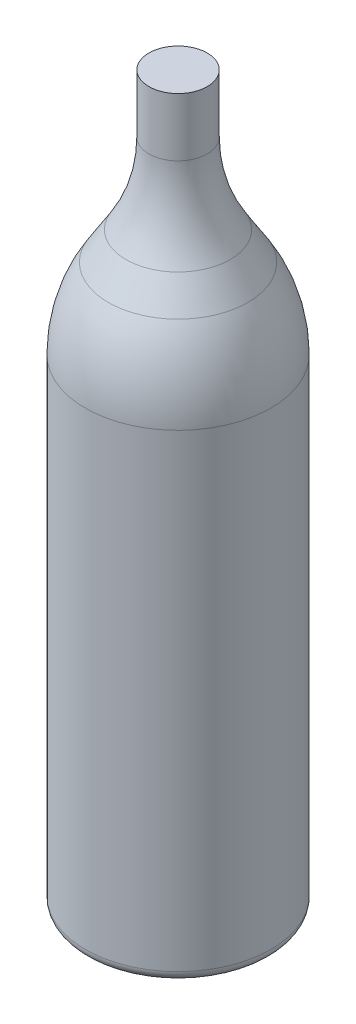
from build123d import *


with BuildPart() as part:
    # Sketch2 → Revolve1 (revolve)
    with BuildSketch(Plane.XY):
        with BuildLine():
            Line((0, 274), (-11, 274))
            Line((-11, 274), (-11, 252))
            ThreePointArc((-11, 252), (-13.208083332, 236.288670718), (-19.661258519, 221.794601939))
            Line((-19.661258519, 221.794601939), (-26.338741481, 211.108395388))
            ThreePointArc((-26.338741481, 211.108395388), (-32.791916668, 196.614326608), (-35, 180.902997327))
            Line((-35, 180.902997327), (-35, 4))
            ThreePointArc((-35, 4), (-33.828427125, 1.171572875), (-31, 0))
            Line((-31, 0), (-29, 0))
            ThreePointArc((-29, 0), (-23.169165423, 1.380991086), (-18.577150935, 5.230558749))
            Line((-18.577150935, 5.230558749), (-8.361917252, 18.934483574))
            ThreePointArc((-8.361917252, 18.934483574), (-4.536719094, 21.540170522), (0, 22.456644901))
            Line((0, 22.456644901), (0, 274))
        make_face()
    revolve(axis=Axis((0, 0, 0), (0, 1, 0)))


solid = part.part
